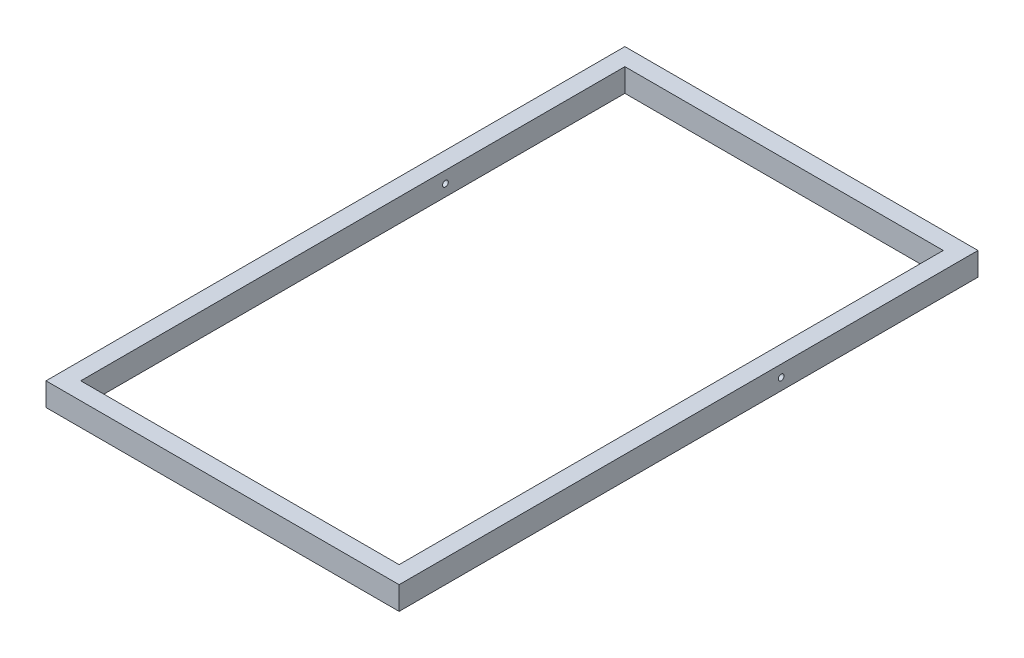
from build123d import *

# Parameters (mm, degrees)
SKETCH_1_W          = 610
SKETCH_1_H          = 1000
SKETCH_1_W_2        = 550
SKETCH_1_H_2        = 940
EXTRUDE_1_DEPTH     = 40
SKETCH_2_R          = 5
CUT_EXTRUDE_1_DEPTH = 611


with BuildPart() as part:
    # Эскиз1 → Бобышка-Вытянуть1 (new body)
    with BuildSketch(Plane(origin=(0, 0, 0), x_dir=(1, 0, 0), z_dir=(0, 1, 0))):
        with Locations((237.034264066, 473.725626833)):
            Rectangle(SKETCH_1_W, SKETCH_1_H)
        with Locations((237.034264066, 473.725626833)):
            Rectangle(SKETCH_1_W_2, SKETCH_1_H_2, mode=Mode.SUBTRACT)
    extrude(amount=EXTRUDE_1_DEPTH)

    # Эскиз2 → Вырез-Вытянуть1 (cut, through all)
    with BuildSketch(Plane(origin=(542.034264066, 0, 0), x_dir=(0, 0, -1), z_dir=(1, 0, 0))):
        with Locations((633.725626833, 20)):
            Circle(SKETCH_2_R)
    extrude(amount=-CUT_EXTRUDE_1_DEPTH, mode=Mode.SUBTRACT)


solid = part.part
